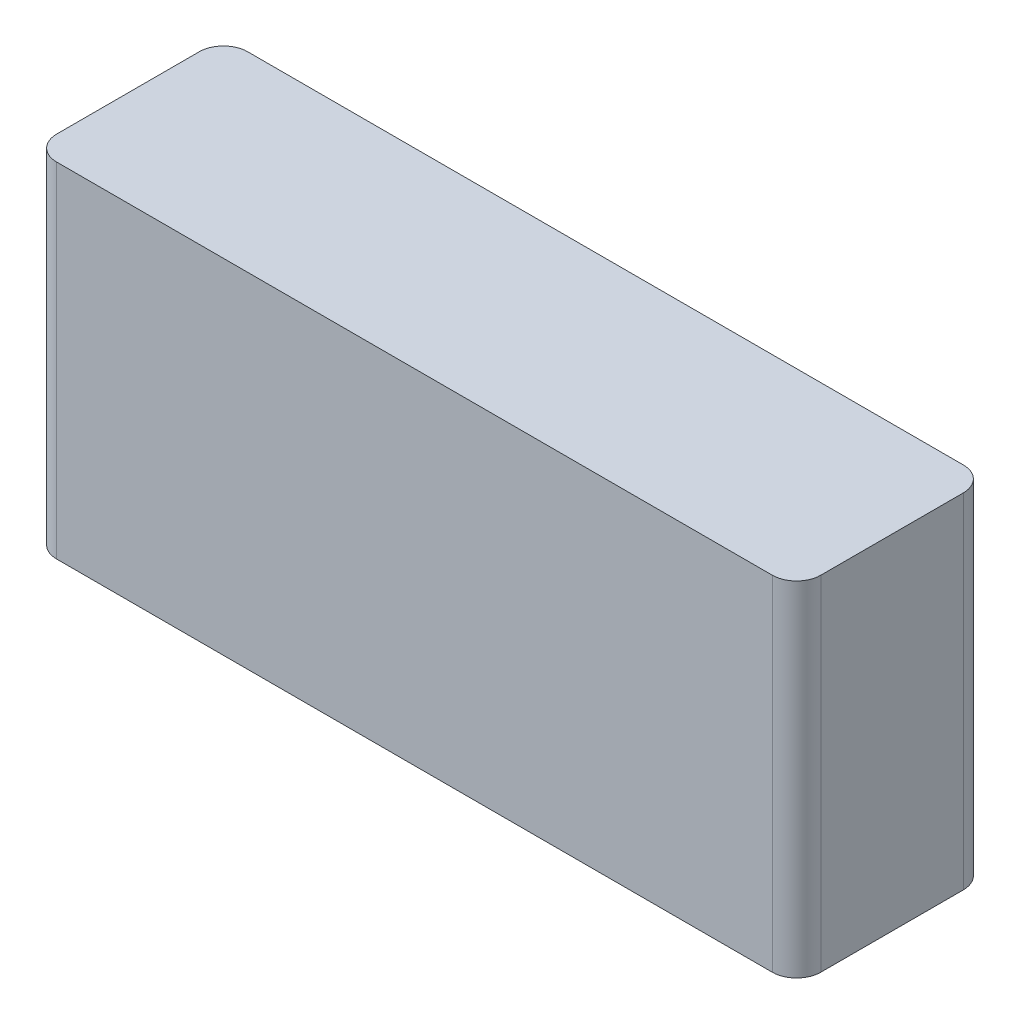
from build123d import *

# Parameters (mm, degrees)
EXTRUDE_1_DEPTH = 36


with BuildPart() as part:
    # 草图1 → 凸台-拉伸1 (new body)
    with BuildSketch(Plane(origin=(0, 0, 0), x_dir=(1, 0, 0), z_dir=(0, 1, 0))):
        with BuildLine():
            Line((-37.46, 10), (37.46, 10))
            ThreePointArc((37.46, 10), (39.256051224, 9.256051224), (40, 7.46))
            Line((40, 7.46), (40, -7.46))
            ThreePointArc((40, -7.46), (39.256051224, -9.256051224), (37.46, -10))
            Line((37.46, -10), (-37.46, -10))
            ThreePointArc((-37.46, -10), (-39.256051224, -9.256051224), (-40, -7.46))
            Line((-40, -7.46), (-40, 7.46))
            ThreePointArc((-40, 7.46), (-39.256051224, 9.256051224), (-37.46, 10))
        make_face()
    extrude(amount=EXTRUDE_1_DEPTH)


solid = part.part
